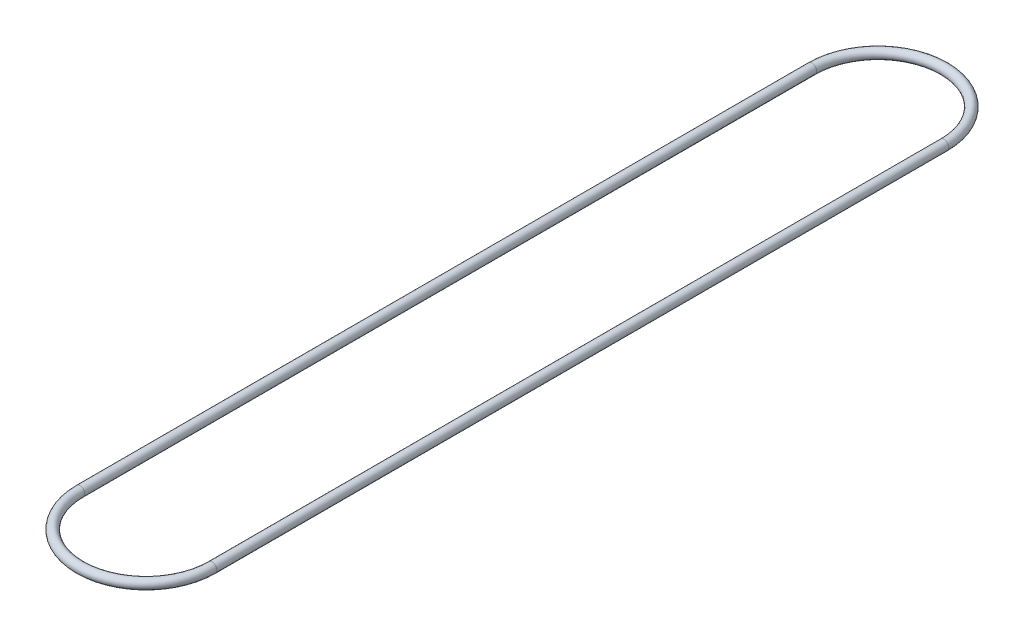
from build123d import *

# Parameters (mm, degrees)
SKETCH2_R = 0.02


with BuildPart() as part:
    # Sweep1: sweep along a path in Sketch1
    with BuildLine(Plane(origin=(0, 2.5, 0), x_dir=(0, 0, -1), z_dir=(0, -1, 0))) as sweep1_path:
        Line((-1.547277937, -0.275), (1.5, -0.275))
        ThreePointArc((1.5, -0.275), (1.775, 0), (1.5, 0.275))
        Line((1.5, 0.275), (-1.547277937, 0.275))
        ThreePointArc((-1.547277937, 0.275), (-1.822277937, 0), (-1.547277937, -0.275))
    # Sketch2 → Sweep1 (sweep)
    with BuildSketch(Plane(origin=(0.270905512, 2.5, -1.547277937), x_dir=(-0.9851109543686638, 0, 0.17191977077363899), z_dir=(0.17191977077363899, 0, 0.9851109543686638))):
        Circle(SKETCH2_R)
    sweep(path=sweep1_path.line)


solid = part.part
